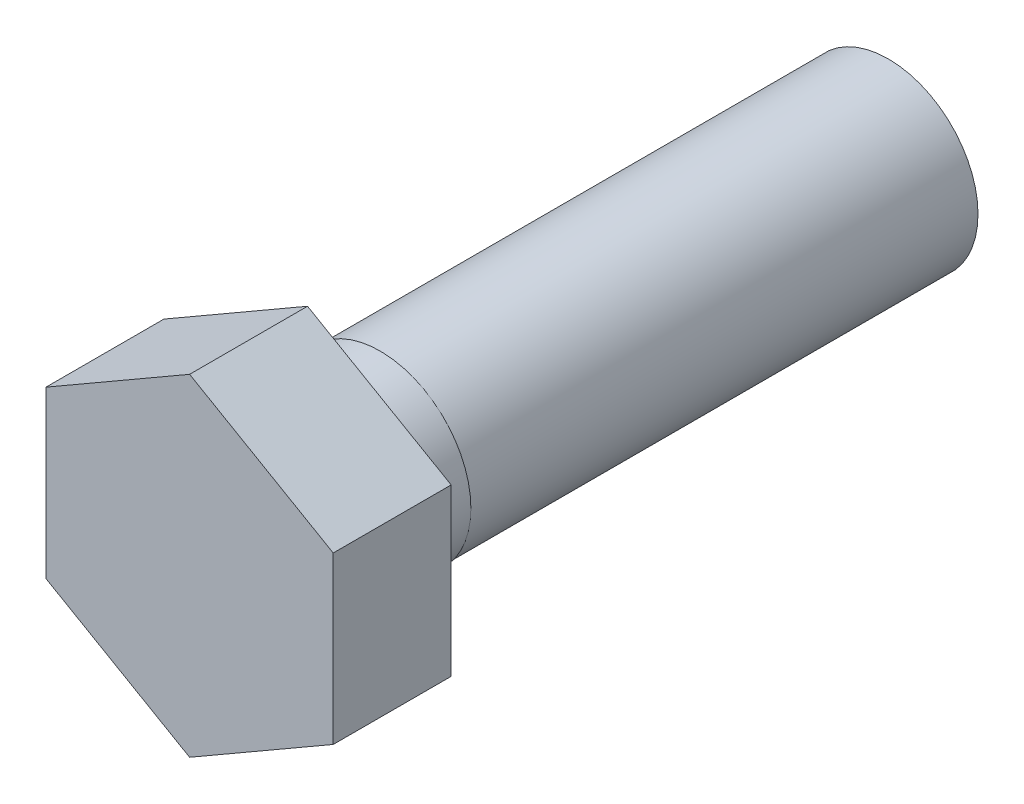
from build123d import *

# Parameters (mm, degrees)
HEAD_DEPTH     = 5.1562
SHANK_SKETCH_R = 3.96875
SHANK_DEPTH    = 25.4
THREAD_END_W   = 22.225
THREAD_END_H   = 0.05


with BuildPart() as part:
    # Head Sketch → Head (new body)
    with BuildSketch(Plane.XY):
        Polygon((0, 7.251692586), (6.28015, 3.625846293), (6.28015, -3.625846293), (0, -7.251692586), (-6.28015, -3.625846293), (-6.28015, 3.625846293), align=None)
    extrude(amount=HEAD_DEPTH)

    # Shank Sketch → Shank (add)
    with BuildSketch(Plane.XY):
        Circle(SHANK_SKETCH_R)
    extrude(amount=-SHANK_DEPTH)

    # Thread End → Thread Cut (revolve, cut)
    with BuildSketch(Plane(origin=(0, 0, 0), x_dir=(0, 0, -1), z_dir=(1, 0, 0))):
        with Locations((14.2875, 3.94375)):
            Rectangle(THREAD_END_W, THREAD_END_H)
    revolve(axis=Axis((0, 0, -21.551935625), (0, 0, -1)), mode=Mode.SUBTRACT)


solid = part.part
